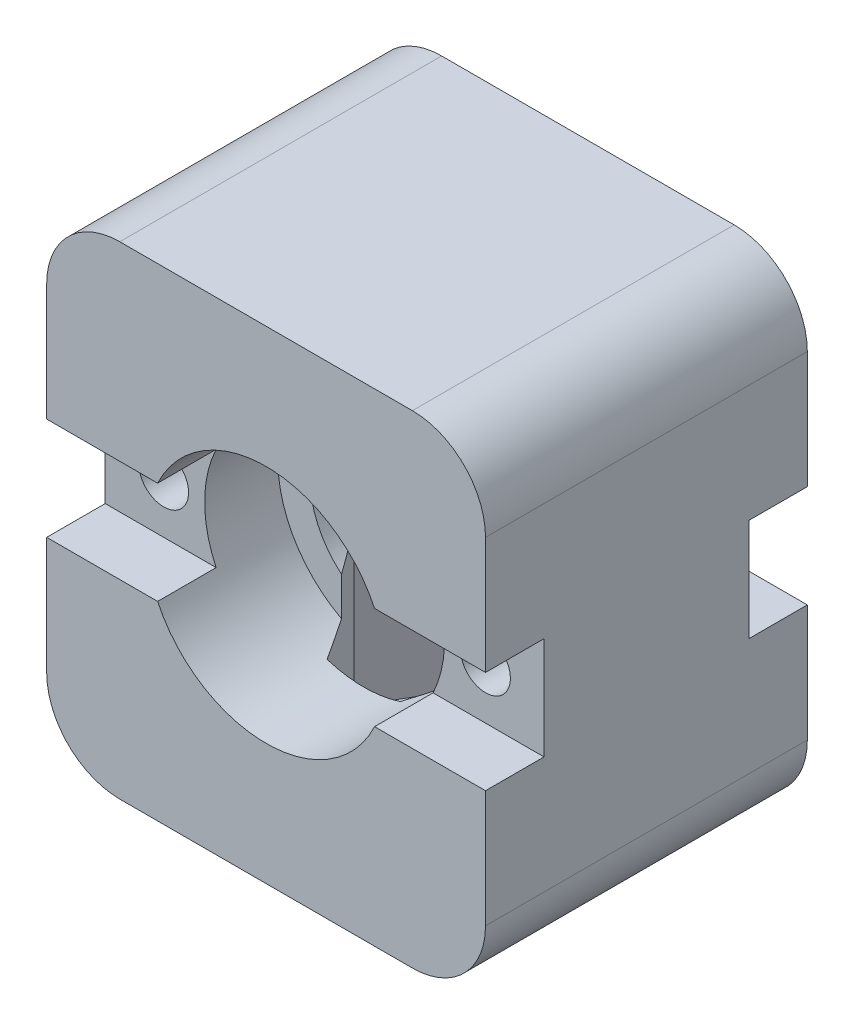
from build123d import *

# Parameters (mm, degrees)
SALIENTE_EXTRUIR2_DEPTH      = 11
SALIENTE_EXTRUIR2_DEPTH_BACK = 11
CROQUIS4_R                   = 6
CROQUIS4_R_2                 = 1.7
CORTAR_EXTRUIR2_DEPTH        = 33
CROQUIS5_R                   = 8.2
CORTAR_EXTRUIR3_DEPTH        = 9
CROQUIS6_W                   = 30.6
CROQUIS6_H                   = 7
CORTAR_EXTRUIR4_DEPTH        = 4
CORTAR_EXTRUIR6_DEPTH        = 14
CROQUIS9_R                   = 2.6
CORTAR_EXTRUIR7_DEPTH        = 5


with BuildPart() as part:
    # Croquis2 → Saliente-Extruir2 (new body, two sides)
    with BuildSketch(Plane.XY) as saliente_extruir2_sk:
        with BuildLine():
            Line((-15, -1.5), (-15, 1.5))
            Line((-15, 1.5), (-15, 11.5))
            ThreePointArc((-15, 11.5), (-13.535533906, 15.035533906), (-10, 16.5))
            Line((-10, 16.5), (10, 16.5))
            ThreePointArc((10, 16.5), (13.535533906, 15.035533906), (15, 11.5))
            Line((15, 11.5), (15, 1.5))
            Line((15, 1.5), (15, -1.5))
            Line((15, -1.5), (15, -11.5))
            ThreePointArc((15, -11.5), (13.535533906, -15.035533906), (10, -16.5))
            Line((10, -16.5), (-10, -16.5))
            ThreePointArc((-10, -16.5), (-13.535533906, -15.035533906), (-15, -11.5))
            Line((-15, -11.5), (-15, -1.5))
        make_face()
    extrude(amount=SALIENTE_EXTRUIR2_DEPTH)
    extrude(saliente_extruir2_sk.sketch, amount=-SALIENTE_EXTRUIR2_DEPTH_BACK)

    # Croquis4 → Cortar-Extruir2 (cut)
    with BuildSketch(Plane(origin=(0, 0, -11), x_dir=(-1, 0, 0), z_dir=(0, 0, -1))):
        Circle(CROQUIS4_R)
        with Locations((-11, 0)):
            Circle(CROQUIS4_R_2)
        with Locations((11, 0)):
            Circle(CROQUIS4_R_2)
    extrude(amount=-CORTAR_EXTRUIR2_DEPTH, mode=Mode.SUBTRACT)

    # Croquis5 → Cortar-Extruir3 (cut)
    with BuildSketch(Plane.XY.offset(11)):
        Circle(CROQUIS5_R)
    cortar_extruir3 = extrude(amount=-CORTAR_EXTRUIR3_DEPTH, mode=Mode.SUBTRACT)

    # Croquis6 → Cortar-Extruir4 (cut)
    with BuildSketch(Plane.XY.offset(11)):
        Rectangle(CROQUIS6_W, CROQUIS6_H)
    cortar_extruir4 = extrude(amount=-CORTAR_EXTRUIR4_DEPTH, mode=Mode.SUBTRACT)

    # Croquis8 → Cortar-Extruir6 (cut)
    with BuildSketch(Plane(origin=(0, 0, 0), x_dir=(1, 0, 0), z_dir=(0, 1, 0))):
        Polygon((5, 0), (2.5, 4.330127019), (-2.5, 4.330127019), (-5, 0), (-2.5, -4.330127019), (2.5, -4.330127019), align=None)
    extrude(amount=-CORTAR_EXTRUIR6_DEPTH, mode=Mode.SUBTRACT)

    # Croquis9 → Cortar-Extruir7 (cut)
    with BuildSketch(Plane.XZ.offset(16.5)):
        Circle(CROQUIS9_R)
    extrude(amount=-CORTAR_EXTRUIR7_DEPTH, mode=Mode.SUBTRACT)

    # Simetr_a1: Cortar-Extruir3, Cortar-Extruir4 across plane
    add(cortar_extruir3.mirror(Plane.XY), mode=Mode.SUBTRACT)
    add(cortar_extruir4.mirror(Plane.XY), mode=Mode.SUBTRACT)


solid = part.part
